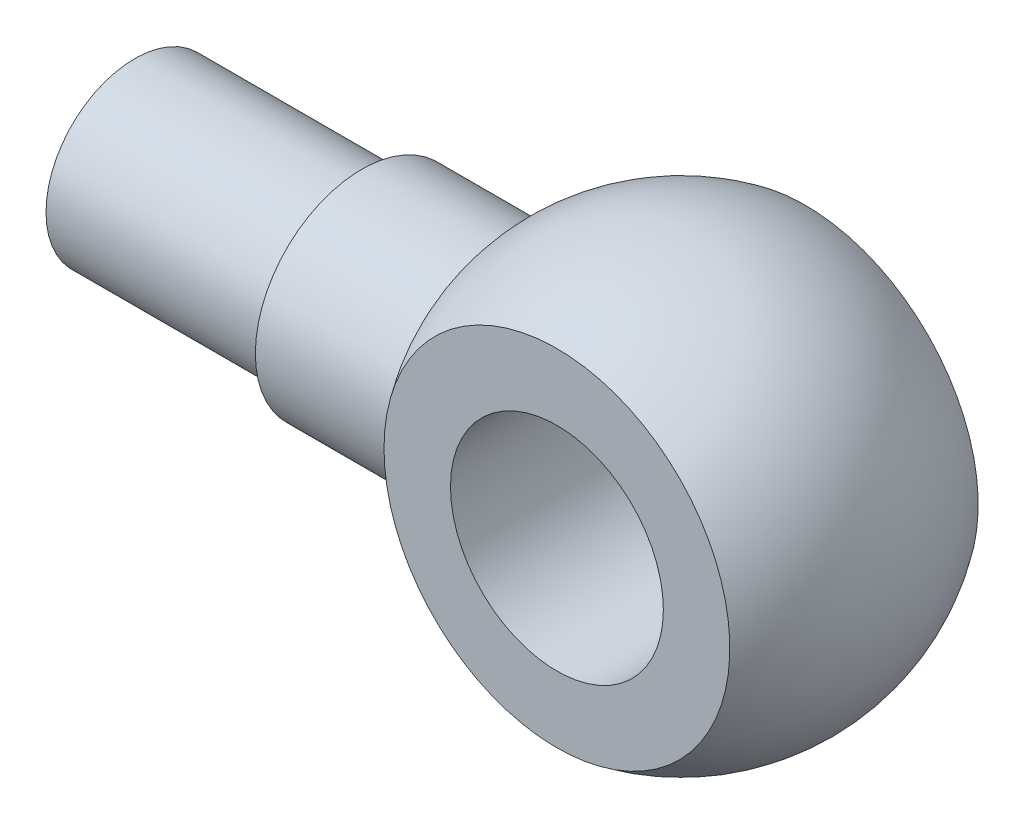
from build123d import *


with BuildPart() as part:
    # Skica1 → Rotovat3 (revolve)
    with BuildSketch(Plane(origin=(0, 0, 0), x_dir=(1, 0, 0), z_dir=(0, 1, 0))):
        Polygon((0, 12.5), (0, 0), (51.019237886, 0), (51.019237886, 15), (32, 15), (32, 12.5), align=None)
    revolve(axis=Axis((-26.278850793, 0, 0), (1, 0, 0)))

    # Skica1_4 → Rotovat4 (revolve)
    with BuildSketch(Plane(origin=(0, 0, 0), x_dir=(1, 0, 0), z_dir=(0, 1, 0))):
        with BuildLine():
            Line((92, 17.5), (92, -17.5))
            Line((92, -17.5), (101.366985862, -17.5))
            ThreePointArc((101.366985862, -17.5), (107, 0), (101.366985862, 17.5))
            Line((101.366985862, 17.5), (92, 17.5))
        make_face()
    revolve(axis=Axis((77, 0, -76.152073434), (0, 0, 1)))


solid = part.part
